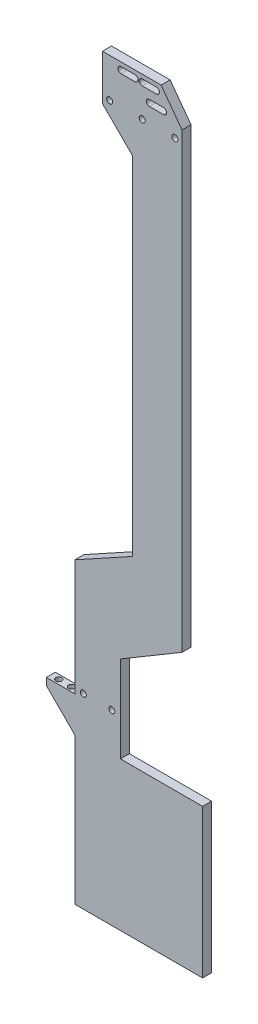
from build123d import *

# Parameters (mm, degrees)
SKETCH1_R           = 2.15
SKETCH1_R_2         = 2.1
BOSS_EXTRUDE1_DEPTH = 6.35
SKETCH2_R           = 2.1
CUT_EXTRUDE1_DEPTH  = 5


with BuildPart() as part:
    # Sketch1 → Boss-Extrude1 (new body)
    with BuildSketch(Plane.XY):
        Polygon((-14.5, 164.786291501), (-29.2, 184.786291501), (-70.5, 184.786291501), (-70.5, 152.786291501), (-49.5, 131.786291501), (-49.5, -112.803421473), (-90, -135.112557197), (-90, -216.825), (-110, -216.825), (-110, -221.825), (-90, -241.825), (-90, -345.112557197), (0, -345.112557197), (0, -240.441757757), (-57.914505889, -240.441757757), (-57.914505889, -179.526253392), (-14.5, -153.791774149), align=None)
        with Locations((-19.5, 157.286291501)):
            Circle(SKETCH1_R, mode=Mode.SUBTRACT)
        with Locations((-42.5, 157.286291501)):
            Circle(SKETCH1_R, mode=Mode.SUBTRACT)
        with Locations((-65.5, 157.286291501)):
            Circle(SKETCH1_R, mode=Mode.SUBTRACT)
        with Locations((-84, -213.65)):
            Circle(SKETCH1_R_2, mode=Mode.SUBTRACT)
        with Locations((-63.914505889, -213.65)):
            Circle(SKETCH1_R_2, mode=Mode.SUBTRACT)
        with BuildLine():
            Line((-42.5, 181.936291501), (-32.5, 181.936291501))
            ThreePointArc((-32.5, 181.936291501), (-30.35, 179.786291501), (-32.5, 177.636291501))
            Line((-32.5, 177.636291501), (-42.5, 177.636291501))
            ThreePointArc((-42.5, 177.636291501), (-44.65, 179.786291501), (-42.5, 181.936291501))
        make_face(mode=Mode.SUBTRACT)
        with BuildLine():
            Line((-57.5, 181.936291501), (-47.5, 181.936291501))
            ThreePointArc((-47.5, 181.936291501), (-45.35, 179.786291501), (-47.5, 177.636291501))
            Line((-47.5, 177.636291501), (-57.5, 177.636291501))
            ThreePointArc((-57.5, 177.636291501), (-59.65, 179.786291501), (-57.5, 181.936291501))
        make_face(mode=Mode.SUBTRACT)
        with BuildLine():
            Line((-37.5, 171.936291501), (-27.5, 171.936291501))
            ThreePointArc((-27.5, 171.936291501), (-25.35, 169.786291501), (-27.5, 167.636291501))
            Line((-27.5, 167.636291501), (-37.5, 167.636291501))
            ThreePointArc((-37.5, 167.636291501), (-39.65, 169.786291501), (-37.5, 171.936291501))
        make_face(mode=Mode.SUBTRACT)
    extrude(amount=BOSS_EXTRUDE1_DEPTH)

    # Sketch2 → Cut-Extrude1 (cut)
    with BuildSketch(Plane(origin=(0, -216.825, 0), x_dir=(-1, 0, 0), z_dir=(0, 1, 0))):
        with Locations((95.5, 3.175)):
            Circle(SKETCH2_R)
        with Locations((104.5, 3.175)):
            Circle(SKETCH2_R)
    extrude(amount=-CUT_EXTRUDE1_DEPTH, mode=Mode.SUBTRACT)


solid = part.part
